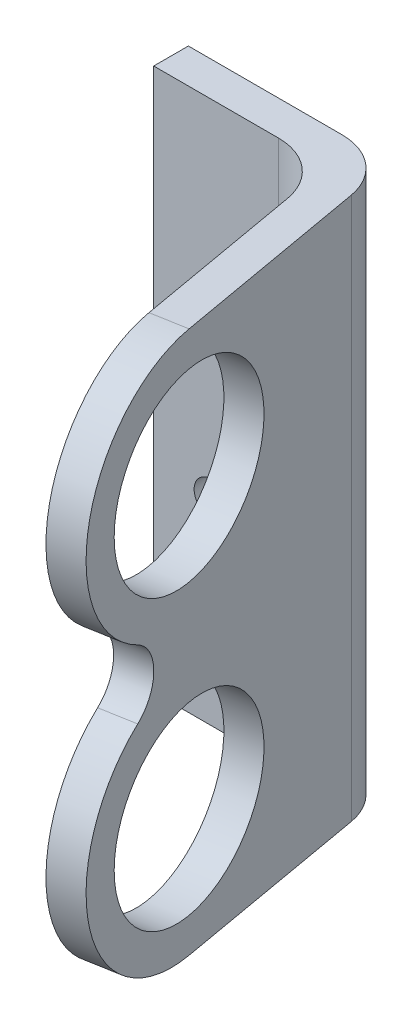
from build123d import *

# Parameters (mm, degrees)
BOSS_EXTRUDE1_DEPTH = 47
SKETCH2_R           = 1.5
CUT_EXTRUDE1_DEPTH  = 4
SKETCH3_R           = 8
CUT_EXTRUDE2_DEPTH  = 9.560785614


with BuildPart() as part:
    # Sketch1 → Boss-Extrude1 (new body)
    with BuildSketch(Plane(origin=(0, 0, 0), x_dir=(1, 0, 0), z_dir=(0, 1, 0))):
        with BuildLine():
            Line((-2.32059976, 10.913457617), (11.001200978, 10.913457617))
            ThreePointArc((11.001200978, 10.913457617), (14.215139026, 9.743679833), (15.925239743, 6.781698506))
            Line((15.925239743, 6.781698506), (20.843268829, -21.10983044))
            Line((20.843268829, -21.10983044), (17.88884557, -21.630774973))
            Line((17.88884557, -21.630774973), (13.407940849, 3.781698506))
            ThreePointArc((13.407940849, 3.781698506), (11.697840132, 6.743679833), (8.483902084, 7.913457617))
            Line((8.483902084, 7.913457617), (-2.32059976, 7.913457617))
            Line((-2.32059976, 7.913457617), (-2.32059976, 10.913457617))
        make_face()
    extrude(amount=BOSS_EXTRUDE1_DEPTH)

    # Sketch2 → Cut-Extrude1 (cut, through all)
    with BuildSketch(Plane.XY.offset(-7.913457617)):
        with Locations((2.67940024, 30)):
            Circle(SKETCH2_R)
        with Locations((2.67940024, 17)):
            Circle(SKETCH2_R)
    extrude(amount=-CUT_EXTRUDE1_DEPTH, mode=Mode.SUBTRACT)

    # Sketch3 → Cut-Extrude2 (cut, through all)
    with BuildSketch(Plane(origin=(13.650350495, 0, -2.406925088), x_dir=(0.173648178, 0, 0.984807753), z_dir=(-0.984807753, 0, 0.173648178))):
        with BuildLine():
            Line((24.408520331, 47), (13.408520331, 47))
            ThreePointArc((13.408520331, 47), (21.186694924, 43.778174593), (24.408520331, 36))
            Line((24.408520331, 36), (24.408520331, 47))
        make_face()
        with BuildLine():
            Line((24.408520331, 0), (24.408520331, 11))
            ThreePointArc((24.408520331, 11), (21.186694924, 3.221825407), (13.408520331, 0))
            Line((13.408520331, 0), (24.408520331, 0))
        make_face()
        with Locations((13.408520331, 11)):
            Circle(SKETCH3_R)
        with Locations((13.408520331, 36)):
            Circle(SKETCH3_R)
        with BuildLine():
            Line((24.408520331, 11), (24.408520331, 36))
            ThreePointArc((24.408520331, 36), (22.930853605, 30.493170692), (18.894853235, 26.465842918))
            ThreePointArc((18.894853235, 26.465842918), (17.17968635, 23.5), (18.894853235, 20.534157082))
            ThreePointArc((18.894853235, 20.534157082), (22.930853605, 16.506829308), (24.408520331, 11))
        make_face()
    extrude(amount=-CUT_EXTRUDE2_DEPTH, mode=Mode.SUBTRACT)


solid = part.part
